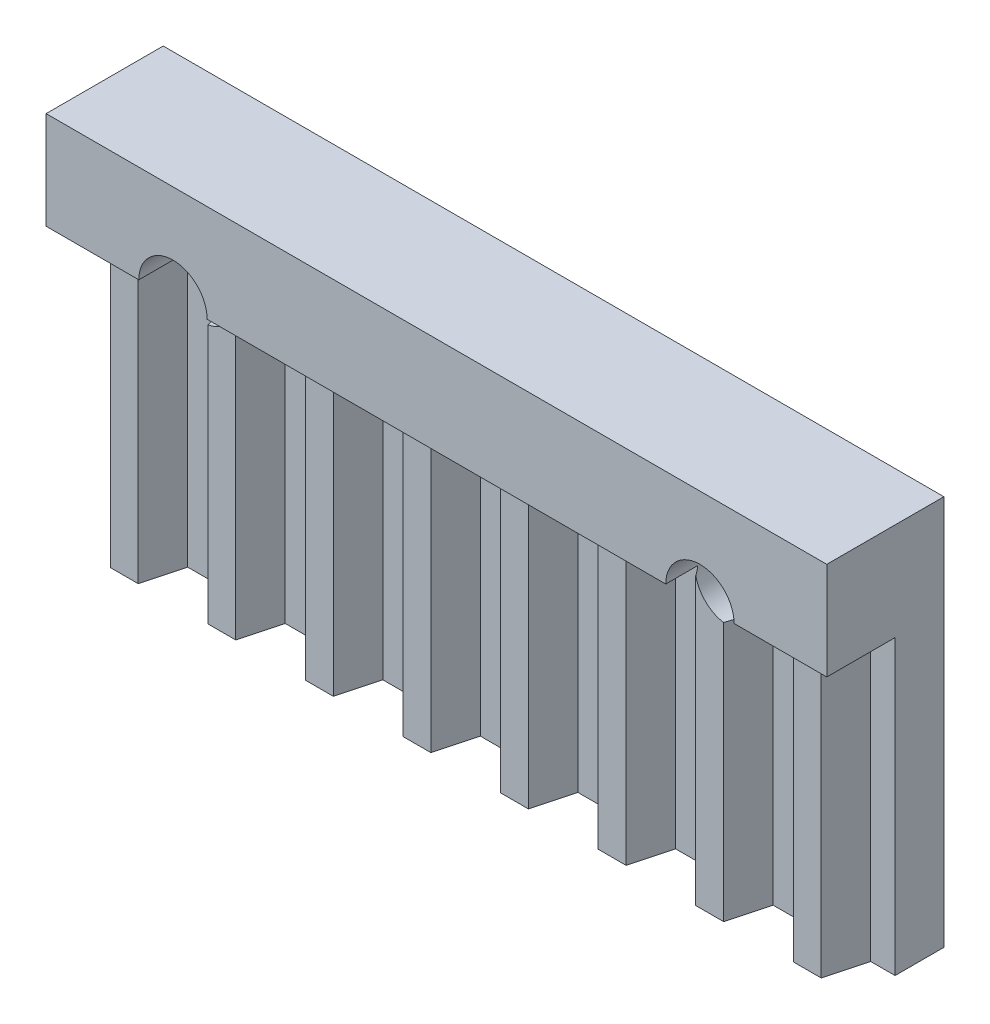
from build123d import *

# Parameters (mm, degrees)
SKETCH_1_W             = 40
SKETCH_1_H             = 20
SKETCH_1_R             = 1.75
EXTRUDE_1_DEPTH        = 6
SKETCH_2_W             = 40
SKETCH_2_H             = 1.5
CUT_EXTRUDE_1_DEPTH    = 15
CUT_EXTRUDE_2_DEPTH    = 15
PATTERN_LINEAR_1_COUNT = 8
PATTERN_LINEAR_1_PITCH = 5


with BuildPart() as part:
    # 草圖1 → 填料-伸長1 (new body)
    with BuildSketch(Plane.XY):
        Rectangle(SKETCH_1_W, SKETCH_1_H)
        with Locations((-13.5, 5)):
            Circle(SKETCH_1_R, mode=Mode.SUBTRACT)
        with Locations((13.5, 5)):
            Circle(SKETCH_1_R, mode=Mode.SUBTRACT)
    extrude(amount=EXTRUDE_1_DEPTH)

    # 草圖2 → 除料-伸長1 (cut)
    with BuildSketch(Plane.XZ.offset(10)):
        with Locations((0, 5.25)):
            Rectangle(SKETCH_2_W, SKETCH_2_H)
    extrude(amount=-CUT_EXTRUDE_1_DEPTH, mode=Mode.SUBTRACT)

    # 草圖3 → 除料-伸長2 (cut)
    with BuildSketch(Plane(origin=(0, -10, 0), x_dir=(-1, 0, 0), z_dir=(0, -1, 0))):
        Polygon((20, -4.5), (18.214101615, -4.5), (18.75, -2.5), (20, -2.5), align=None)
        Polygon((16.785898385, -4.5), (16.25, -2.5), (15, -2.5), (15, -4.5), align=None)
    cut_extrude_2 = extrude(amount=-CUT_EXTRUDE_2_DEPTH, mode=Mode.SUBTRACT)

    # 直線複製排列1: 除料-伸長2 ×8
    with Locations(*[(i * PATTERN_LINEAR_1_PITCH, 0, 0) for i in range(1, PATTERN_LINEAR_1_COUNT)]):
        add(cut_extrude_2, mode=Mode.SUBTRACT)


solid = part.part
